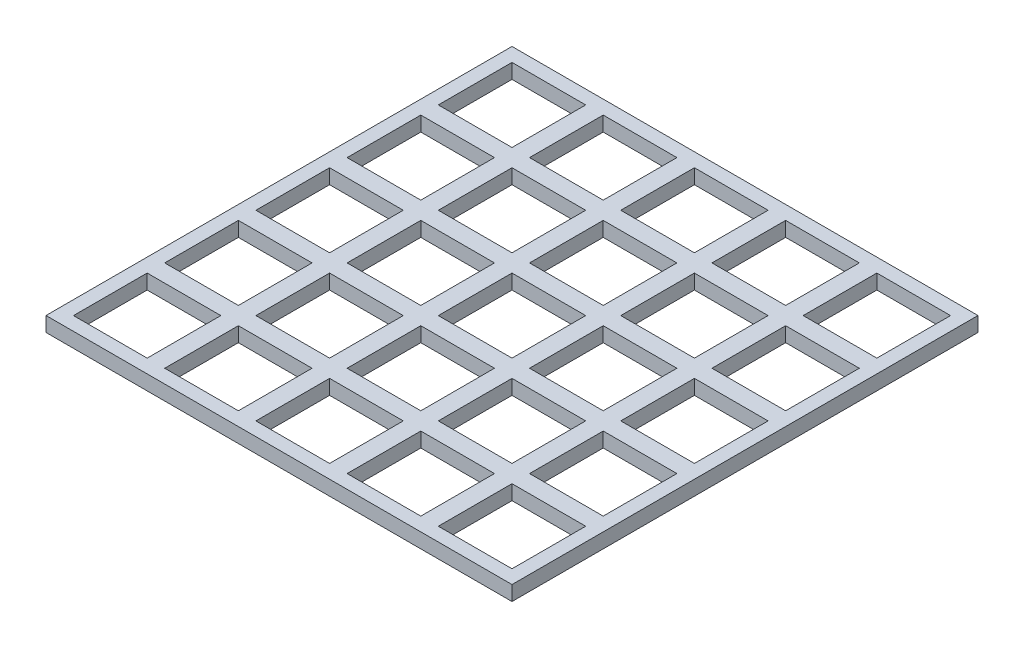
from build123d import *

# Parameters (mm, degrees)
SKETCH3_W           = 63.25
SKETCH3_H           = 63.25
SKETCH3_W_2         = 10
SKETCH3_H_2         = 10
BOSS_EXTRUDE3_DEPTH = 2


with BuildPart() as part:
    # Sketch3 → Boss-Extrude3 (new body)
    with BuildSketch(Plane(origin=(0, 0, 0), x_dir=(1, 0, 0), z_dir=(0, 1, 0))):
        with Locations((0.125, 0.125)):
            Rectangle(SKETCH3_W, SKETCH3_H)
        with Locations((-12.245, 24.875)):
            Rectangle(SKETCH3_W_2, SKETCH3_H_2, mode=Mode.SUBTRACT)
        with Locations((-24.625, 24.875)):
            Rectangle(SKETCH3_W_2, SKETCH3_H_2, mode=Mode.SUBTRACT)
        with Locations((0.135, 24.875)):
            Rectangle(SKETCH3_W_2, SKETCH3_H_2, mode=Mode.SUBTRACT)
        with Locations((12.515, 24.875)):
            Rectangle(SKETCH3_W_2, SKETCH3_H_2, mode=Mode.SUBTRACT)
        with Locations((24.895, 24.875)):
            Rectangle(SKETCH3_W_2, SKETCH3_H_2, mode=Mode.SUBTRACT)
        with Locations((-12.245, 12.495)):
            Rectangle(SKETCH3_W_2, SKETCH3_H_2, mode=Mode.SUBTRACT)
        with Locations((0.135, 12.495)):
            Rectangle(SKETCH3_W_2, SKETCH3_H_2, mode=Mode.SUBTRACT)
        with Locations((12.515, 12.495)):
            Rectangle(SKETCH3_W_2, SKETCH3_H_2, mode=Mode.SUBTRACT)
        with Locations((24.895, 12.495)):
            Rectangle(SKETCH3_W_2, SKETCH3_H_2, mode=Mode.SUBTRACT)
        with Locations((-12.245, 0.115)):
            Rectangle(SKETCH3_W_2, SKETCH3_H_2, mode=Mode.SUBTRACT)
        with Locations((0.135, 0.115)):
            Rectangle(SKETCH3_W_2, SKETCH3_H_2, mode=Mode.SUBTRACT)
        with Locations((12.515, 0.115)):
            Rectangle(SKETCH3_W_2, SKETCH3_H_2, mode=Mode.SUBTRACT)
        with Locations((24.895, 0.115)):
            Rectangle(SKETCH3_W_2, SKETCH3_H_2, mode=Mode.SUBTRACT)
        with Locations((-12.245, -12.265)):
            Rectangle(SKETCH3_W_2, SKETCH3_H_2, mode=Mode.SUBTRACT)
        with Locations((0.135, -12.265)):
            Rectangle(SKETCH3_W_2, SKETCH3_H_2, mode=Mode.SUBTRACT)
        with Locations((12.515, -12.265)):
            Rectangle(SKETCH3_W_2, SKETCH3_H_2, mode=Mode.SUBTRACT)
        with Locations((24.895, -12.265)):
            Rectangle(SKETCH3_W_2, SKETCH3_H_2, mode=Mode.SUBTRACT)
        with Locations((-12.245, -24.645)):
            Rectangle(SKETCH3_W_2, SKETCH3_H_2, mode=Mode.SUBTRACT)
        with Locations((0.135, -24.645)):
            Rectangle(SKETCH3_W_2, SKETCH3_H_2, mode=Mode.SUBTRACT)
        with Locations((12.515, -24.645)):
            Rectangle(SKETCH3_W_2, SKETCH3_H_2, mode=Mode.SUBTRACT)
        with Locations((24.895, -24.645)):
            Rectangle(SKETCH3_W_2, SKETCH3_H_2, mode=Mode.SUBTRACT)
        with Locations((-24.625, 12.495)):
            Rectangle(SKETCH3_W_2, SKETCH3_H_2, mode=Mode.SUBTRACT)
        with Locations((-24.625, 0.115)):
            Rectangle(SKETCH3_W_2, SKETCH3_H_2, mode=Mode.SUBTRACT)
        with Locations((-24.625, -12.265)):
            Rectangle(SKETCH3_W_2, SKETCH3_H_2, mode=Mode.SUBTRACT)
        with Locations((-24.625, -24.645)):
            Rectangle(SKETCH3_W_2, SKETCH3_H_2, mode=Mode.SUBTRACT)
    extrude(amount=BOSS_EXTRUDE3_DEPTH)


solid = part.part
